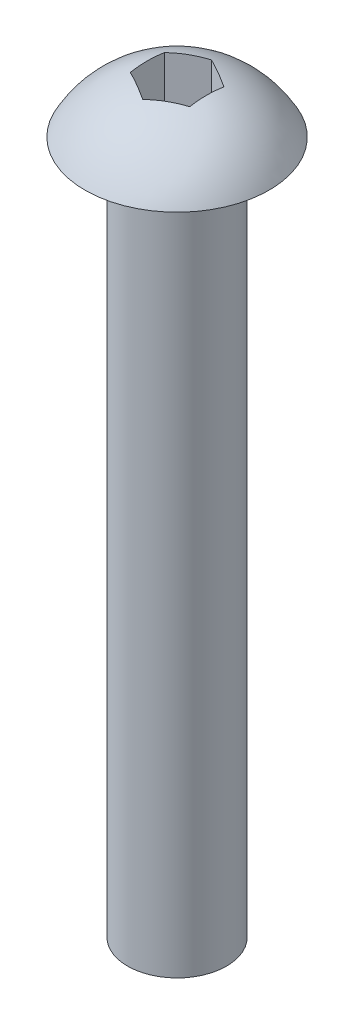
from build123d import *

# Parameters (mm, degrees)
CUT_EXTRUDE1_DEPTH = 10


with BuildPart() as part:
    # Sketch1 → Revolve1 (revolve)
    with BuildSketch(Plane.XY):
        with BuildLine():
            Line((0, 0), (0, -35))
            Line((0, -35), (2.5, -35))
            Line((2.5, -35), (2.5, 0))
            Line((2.5, 0), (4.65, 0))
            ThreePointArc((4.65, 0), (2.713968497, 2.045965539), (0, 2.8))
            Line((0, 2.8), (0, 0))
        make_face()
    revolve(axis=Axis((0, 0, 0), (0, -1, 0)))

    # Sketch2 → Cut-Extrude1 (cut)
    with BuildSketch(Plane(origin=(0, 0, 0), x_dir=(1, 0, 0), z_dir=(0, 1, 0))):
        Polygon((0, 1.732050808), (-1.5, 0.866025404), (-1.5, -0.866025404), (0, -1.732050808), (1.5, -0.866025404), (1.5, 0.866025404), align=None)
    extrude(amount=CUT_EXTRUDE1_DEPTH, mode=Mode.SUBTRACT)


solid = part.part
